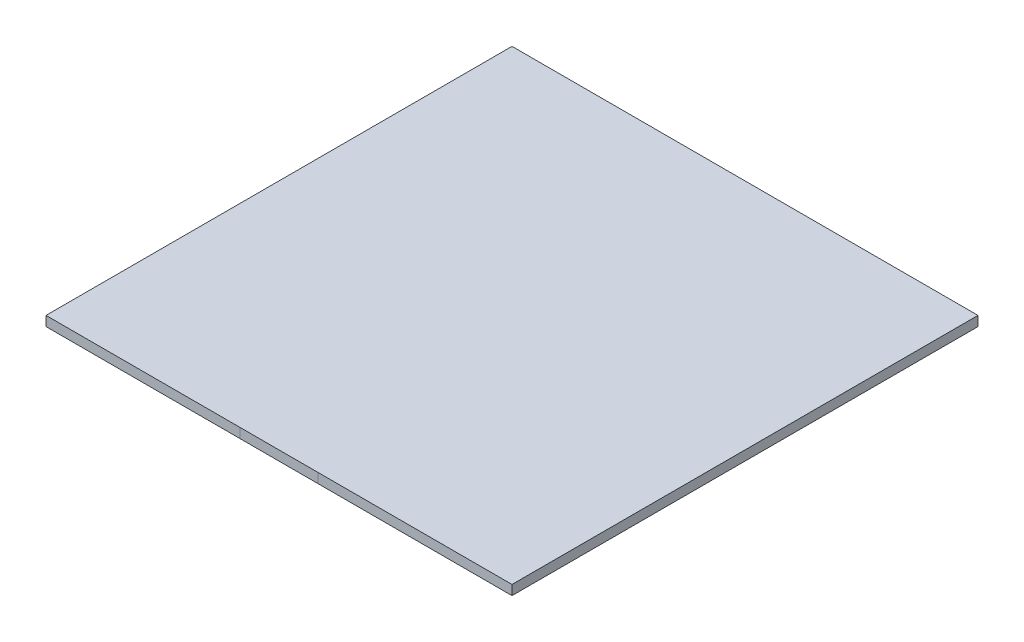
from build123d import *

# Parameters (mm, degrees)
SKETCH2_W           = 152.4
SKETCH2_H           = 3.175
BOSS_EXTRUDE1_DEPTH = 152.4


with BuildPart() as part:
    # Sketch2 → Boss-Extrude1 (new body)
    with BuildSketch(Plane.XY):
        with Locations((76.2, -1.5875)):
            Rectangle(SKETCH2_W, SKETCH2_H)
    extrude(amount=BOSS_EXTRUDE1_DEPTH)


solid = part.part
